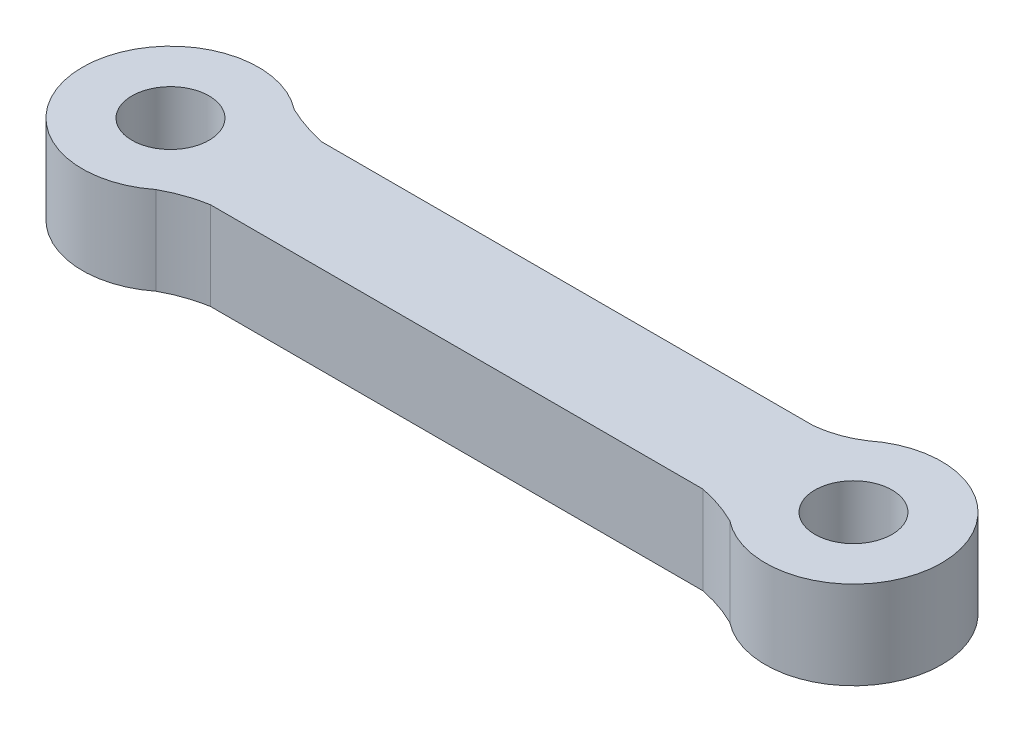
from build123d import *

# Parameters (mm, degrees)
CROQUIS1_R              = 1.75
SALIENTE_EXTRUIR1_DEPTH = 4


with BuildPart() as part:
    # Croquis1 → Saliente-Extruir1 (new body)
    with BuildSketch(Plane(origin=(0, 0, 0), x_dir=(1, 0, 0), z_dir=(0, 1, 0))):
        with BuildLine():
            Line((-11.167093962, 2.499461471), (11.171906038, 2.499461471))
            add(Edge.make_bspline(
                [(11.171906038, 2.499461471), (12.207826719, 2.608902185), (13.014633598, 3.14028172)],
                knots=[0, 0, 0, 0.652329484, 0.652329484, 0.652329484], degree=2))
            ThreePointArc((13.014633598, 3.14028172), (19.501897093, 0.016094387), (13.027906038, -3.135504249))
            add(Edge.make_bspline(
                [(11.171906038, -2.500538529), (12.163350933, -2.700124356), (13.027906038, -3.135504249)],
                knots=[0, 0, 0, 0.381033485, 0.381033485, 0.381033485], degree=2))
            Line((11.171906038, -2.500538529), (-11.176720188, -2.500538529))
            add(Edge.make_bspline(
                [(-11.176720188, -2.500538529), (-12.181502866, -2.673255137), (-13.0255, -3.143139195)],
                knots=[0, 0, 0, 0.480047459, 0.480047459, 0.480047459], degree=2))
            ThreePointArc((-13.0255, -3.143139195), (-19.4995, 0), (-13.0255, 3.143139195))
            add(Edge.make_bspline(
                [(-11.167093962, 2.499461471), (-12.150237992, 2.727686633), (-13.0255, 3.143139195)],
                knots=[0, 0, 0, 0.309192528, 0.309192528, 0.309192528], degree=2))
        make_face()
        with Locations((-15.4995, 0)):
            Circle(CROQUIS1_R, mode=Mode.SUBTRACT)
        with Locations((15.501906038, 0.007634946)):
            Circle(CROQUIS1_R, mode=Mode.SUBTRACT)
    extrude(amount=SALIENTE_EXTRUIR1_DEPTH)


solid = part.part
